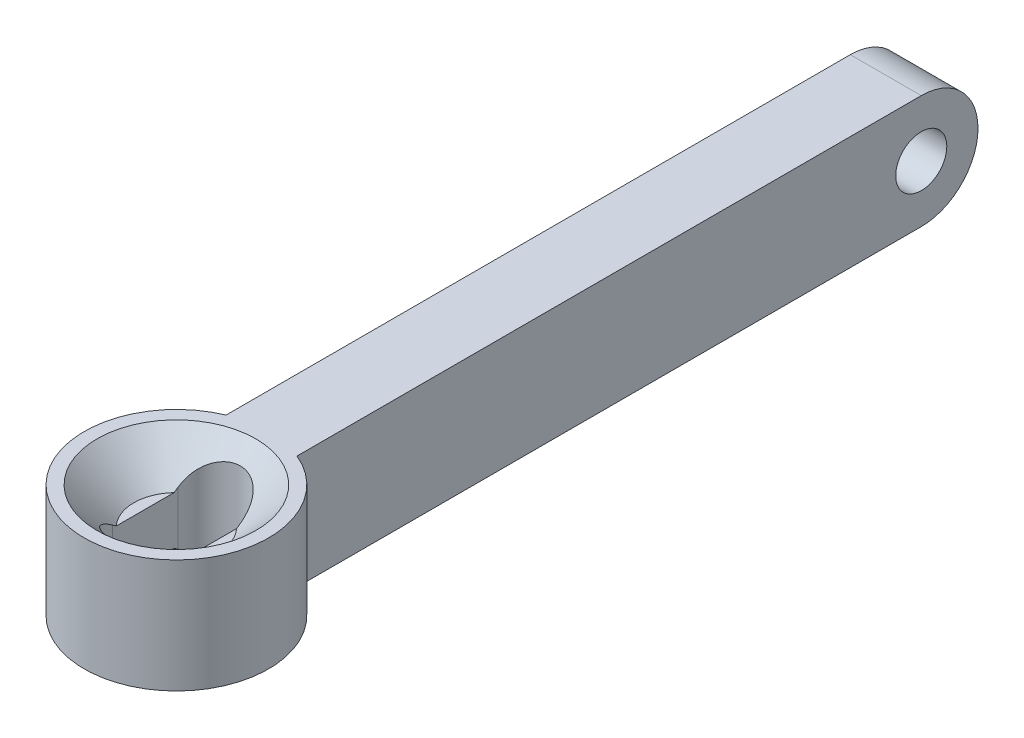
from build123d import *

# Parameters (mm, degrees)
SKETCH1_R      = 3.25
EXTRUDE1_DEPTH = 4
SKETCH2_R      = 0.9
EXTRUDE2_DEPTH = 1.25


with BuildPart() as part:
    # Sketch1 → Extrude1 (new body)
    with BuildSketch(Plane(origin=(0, 0, 0), x_dir=(1, 0, 0), z_dir=(0, 1, 0))):
        with Locations(Location((0, 0, 0), (0, 0, 270))):  # turned: the seam where the file's is
            Circle(SKETCH1_R)
        with BuildLine():
            Line((1.1, 1.15), (1.1, -1.15))
            ThreePointArc((1.1, -1.15), (0, -2.25), (-1.1, -1.15))
            Line((-1.1, -1.15), (-1.1, 1.15))
            ThreePointArc((-1.1, 1.15), (0, 2.25), (1.1, 1.15))
        make_face(mode=Mode.SUBTRACT)
    extrude(amount=EXTRUDE1_DEPTH)

    # Sketch2 → Extrude2 (add, symmetric)
    with BuildSketch(Plane(origin=(0, 0, 0), x_dir=(0, 0, -1), z_dir=(1, 0, 0))):
        with BuildLine():
            Line((3, 4), (3, 0))
            Line((3, 0), (25, 0))
            ThreePointArc((25, 0), (27, 2), (25, 4))
            Line((25, 4), (3, 4))
        make_face()
        with Locations((25, 2)):
            Circle(SKETCH2_R, mode=Mode.SUBTRACT)
    extrude(amount=EXTRUDE2_DEPTH, both=True)

    # Sketch4 → Cut-Revolve1 (revolve, cut)
    with BuildSketch(Plane(origin=(0, 0, 0), x_dir=(0, 0, -1), z_dir=(1, 0, 0))):
        Polygon((0, 2.7), (1.5, 2.7), (2.8, 4), (0, 4), align=None)
        Polygon((0, 1), (1.5, 1), (2.5, 0), (0, 0), align=None)
    revolve(axis=Axis((0, 0, 0), (0, 1, 0)), mode=Mode.SUBTRACT)


solid = part.part
